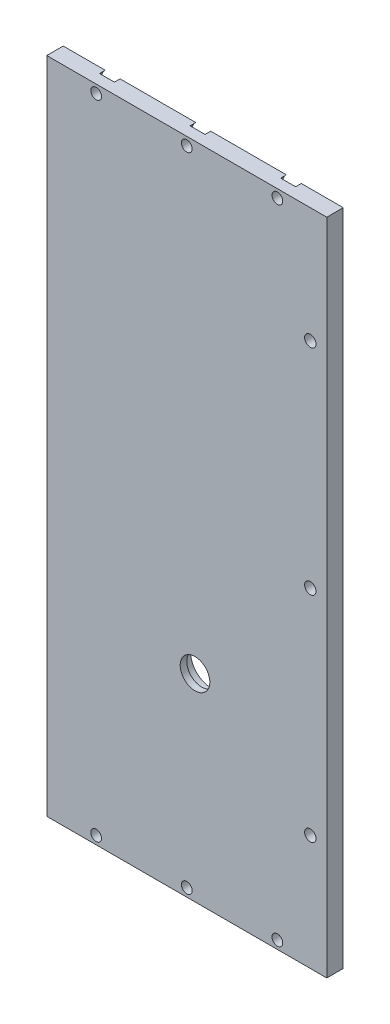
from build123d import *

# Parameters (mm, degrees)
SKETCH1_W                                           = 85
SKETCH1_H                                           = 200
BOSS_EXTRUDE1_DEPTH                                 = 5
CBORE_FOR_4_BINDING_HEAD_MACHINE_SCREW1_D           = 3.4544
CBORE_FOR_4_BINDING_HEAD_MACHINE_SCREW1_CBORE_D     = 6.74624
CBORE_FOR_4_BINDING_HEAD_MACHINE_SCREW1_CBORE_DEPTH = 1.7272
CBORE_FOR_4_BINDING_HEAD_MACHINE_SCREW2_D           = 3.2639
CBORE_FOR_4_BINDING_HEAD_MACHINE_SCREW2_DEPTH       = 5
CBORE_FOR_4_BINDING_HEAD_MACHINE_SCREW2_CBORE_D     = 6.74624
CBORE_FOR_4_BINDING_HEAD_MACHINE_SCREW2_CBORE_DEPTH = 1.7272
F_4_40_TAPPED_HOLE2_D                               = 2.2606
F_4_40_TAPPED_HOLE2_DEPTH                           = 7.6
F_4_40_TAPPED_HOLE2_TIP                             = 0.679152758
SKETCH10_R                                          = 4.5
CUT_EXTRUDE2_DEPTH                                  = 6
SKETCH10_6_R                                        = 6.35
CUT_EXTRUDE3_DEPTH                                  = 3


with BuildPart() as part:
    # Sketch1 → Boss-Extrude1 (new body)
    with BuildSketch(Plane.XY):
        with Locations((-115.863171355, -8.158567775)):
            Rectangle(SKETCH1_W, SKETCH1_H)
    extrude(amount=BOSS_EXTRUDE1_DEPTH)

    # CBORE for _4 Binding Head Machine Screw1 (through all)
    with Locations(Plane(origin=(0, 0, 0), x_dir=(-1, 0, 0), z_dir=(0, 0, -1))):
        with Locations((78.363171355, 56.841432225), (78.363171355, -8.158567775), (78.363171355, -73.158567775)):
            CounterBoreHole(CBORE_FOR_4_BINDING_HEAD_MACHINE_SCREW1_D / 2, CBORE_FOR_4_BINDING_HEAD_MACHINE_SCREW1_CBORE_D / 2, CBORE_FOR_4_BINDING_HEAD_MACHINE_SCREW1_CBORE_DEPTH)

    # CBORE for _4 Binding Head Machine Screw2
    with Locations(Plane(origin=(0, 0, 0), x_dir=(-1, 0, 0), z_dir=(0, 0, -1))):
        with Locations((88.363171355, 89.341432225), (115.863171355, 89.341432225), (143.363171355, 89.341432225), (143.363171355, -105.658567775), (115.863171355, -105.658567775), (88.363171355, -105.658567775)):
            CounterBoreHole(CBORE_FOR_4_BINDING_HEAD_MACHINE_SCREW2_D / 2, CBORE_FOR_4_BINDING_HEAD_MACHINE_SCREW2_CBORE_D / 2, CBORE_FOR_4_BINDING_HEAD_MACHINE_SCREW2_CBORE_DEPTH, depth=CBORE_FOR_4_BINDING_HEAD_MACHINE_SCREW2_DEPTH)

    # 4-40 Tapped Hole2
    with Locations(Plane.ZY.offset(158.363171355)):
        with Locations((2.5, -58.158567775), (2.5, 41.841432225)):
            Hole(F_4_40_TAPPED_HOLE2_D / 2, depth=F_4_40_TAPPED_HOLE2_DEPTH)
            with Locations((0, 0, -(F_4_40_TAPPED_HOLE2_DEPTH + F_4_40_TAPPED_HOLE2_TIP / 2))):  # 118° drill point
                Cone(0, F_4_40_TAPPED_HOLE2_D / 2, F_4_40_TAPPED_HOLE2_TIP, mode=Mode.SUBTRACT)

    # Sketch10 → Cut-Extrude2 (cut, through all)
    with BuildSketch(Plane(origin=(0, 0, 0), x_dir=(-1, 0, 0), z_dir=(0, 0, -1))):
        with Locations((113.363171355, -48.158567775)):
            Circle(SKETCH10_R)
    extrude(amount=-CUT_EXTRUDE2_DEPTH, mode=Mode.SUBTRACT)

    # Sketch10_6 → Cut-Extrude3 (cut)
    with BuildSketch(Plane(origin=(0, 0, 0), x_dir=(-1, 0, 0), z_dir=(0, 0, -1))):
        with Locations((113.363171355, -48.158567775)):
            Circle(SKETCH10_6_R)
    extrude(amount=-CUT_EXTRUDE3_DEPTH, mode=Mode.SUBTRACT)


solid = part.part
